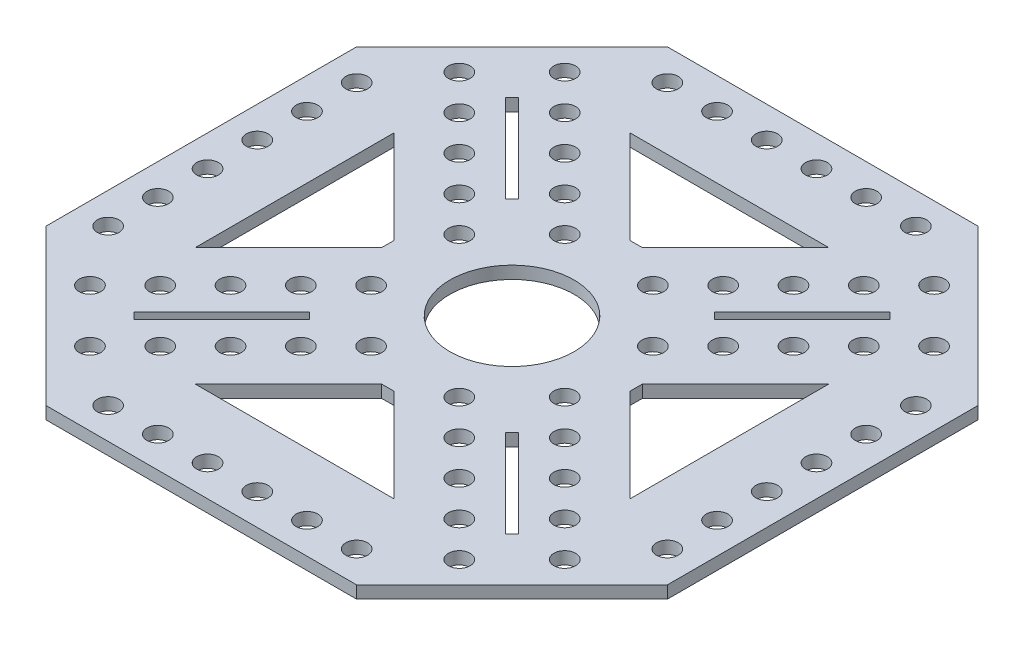
from build123d import *

# Parameters (mm, degrees)
BOSS_EXTRUDE1_DEPTH = 2
SKETCH3_R           = 10
CUT_EXTRUDE2_DEPTH  = 2
SKETCH2_R           = 1.75
CUT_EXTRUDE1_DEPTH  = 2
SKETCH4_R           = 1.75
CUT_EXTRUDE3_DEPTH  = 2
CIRPATTERN1_COUNT   = 4


with BuildPart() as part:
    # Sketch1 → Boss-Extrude1 (new body)
    with BuildSketch(Plane(origin=(0, 0, 0), x_dir=(1, 0, 0), z_dir=(0, 1, 0))):
        Polygon((-25, 50), (25, 50), (50, 25), (50, -25), (25, -50), (-25, -50), (-50, -25), (-50, 25), align=None)
    extrude(amount=BOSS_EXTRUDE1_DEPTH)

    # Sketch3 → Cut-Extrude2 (cut)
    with BuildSketch(Plane(origin=(0, 2, 0), x_dir=(1, 0, 0), z_dir=(0, 1, 0))):
        Circle(SKETCH3_R)
    extrude(amount=-CUT_EXTRUDE2_DEPTH, mode=Mode.SUBTRACT)

    # Sketch2 → Cut-Extrude1 (cut)
    with BuildSketch(Plane(origin=(0, 2, 0), x_dir=(1, 0, 0), z_dir=(0, 1, 0))):
        with Locations((-45, 20)):
            Circle(SKETCH2_R)
        with Locations((-45, 12)):
            Circle(SKETCH2_R)
        with Locations((-45, 4)):
            Circle(SKETCH2_R)
        with Locations((-45, -4)):
            Circle(SKETCH2_R)
        with Locations((-45, -12)):
            Circle(SKETCH2_R)
        with Locations((-45, -20)):
            Circle(SKETCH2_R)
    cut_extrude1 = extrude(amount=-CUT_EXTRUDE1_DEPTH, mode=Mode.SUBTRACT)

    # Sketch4 → Cut-Extrude3 (cut)
    with BuildSketch(Plane(origin=(0, 2, 0), x_dir=(1, 0, 0), z_dir=(0, 1, 0))):
        with Locations((-29.721825407, 38.207106781)):
            Circle(SKETCH4_R)
        with Locations((-24.064971157, 32.550252532)):
            Circle(SKETCH4_R)
        with Locations((-18.408116908, 26.893398282)):
            Circle(SKETCH4_R)
        with Locations((-12.751262658, 21.236544033)):
            Circle(SKETCH4_R)
        with Locations((-7.094408409, 15.579689783)):
            Circle(SKETCH4_R)
        with Locations((-15.579689783, 7.094408409)):
            Circle(SKETCH4_R)
        with Locations((-21.236544033, 12.751262658)):
            Circle(SKETCH4_R)
        with Locations((-26.893398282, 18.408116908)):
            Circle(SKETCH4_R)
        with Locations((-32.550252532, 24.064971157)):
            Circle(SKETCH4_R)
        with Locations((-38.207106781, 29.721825407)):
            Circle(SKETCH4_R)
        Polygon((-30.959262274, 29.898602102), (-16.81712665, 15.756466479), (-15.756466479, 16.81712665), (-29.898602102, 30.959262274), align=None)
        Polygon((-35, 16), (-20, 1), (-20, -1), (-35, -16), align=None)
    cut_extrude3 = extrude(amount=-CUT_EXTRUDE3_DEPTH, mode=Mode.SUBTRACT)

    # CirPattern1: Cut-Extrude1, Cut-Extrude3 ×4 about axis
    cirpattern1_axis = Axis((0, 0, 0), (0, 1, 0))
    for i in range(1, CIRPATTERN1_COUNT):
        add(cut_extrude1.rotate(cirpattern1_axis, i * 360 / CIRPATTERN1_COUNT), mode=Mode.SUBTRACT)
        add(cut_extrude3.rotate(cirpattern1_axis, i * 360 / CIRPATTERN1_COUNT), mode=Mode.SUBTRACT)


solid = part.part
